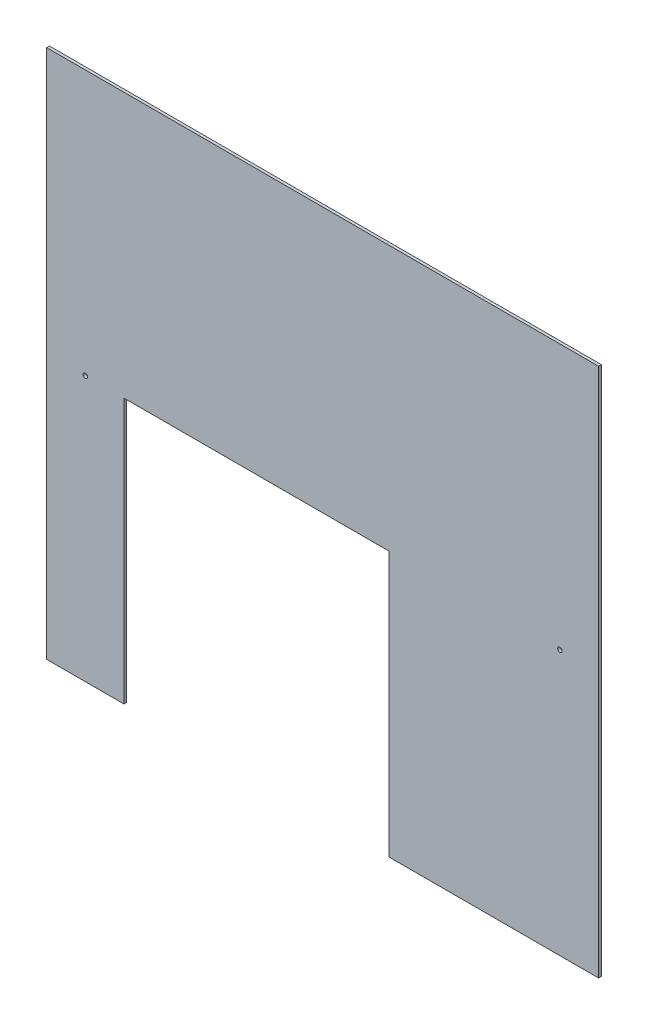
from build123d import *

# Parameters (mm, degrees)
BOSS_EXTRUDE1_DEPTH = 3.175
SKETCH2_R           = 2.5796875
CUT_EXTRUDE1_DEPTH  = 3.175


with BuildPart() as part:
    # Sketch1 → Boss-Extrude1 (new body)
    with BuildSketch(Plane.XY):
        Polygon((-630.182303707, 436.398885794), (4.817696293, 436.398885794), (4.817696293, -173.201114206), (-236.482303707, -173.201114206), (-236.482303707, 131.598885794), (-541.282303707, 131.598885794), (-541.282303707, -173.201114206), (-630.182303707, -173.201114206), align=None)
    extrude(amount=BOSS_EXTRUDE1_DEPTH)

    # Sketch2 → Cut-Extrude1 (cut)
    with BuildSketch(Plane.XY.offset(3.175)):
        with Locations((-585.732303707, 131.598885794)):
            Circle(SKETCH2_R)
        with Locations((-39.632303707, 131.598885794)):
            Circle(SKETCH2_R)
    extrude(amount=-CUT_EXTRUDE1_DEPTH, mode=Mode.SUBTRACT)


solid = part.part
